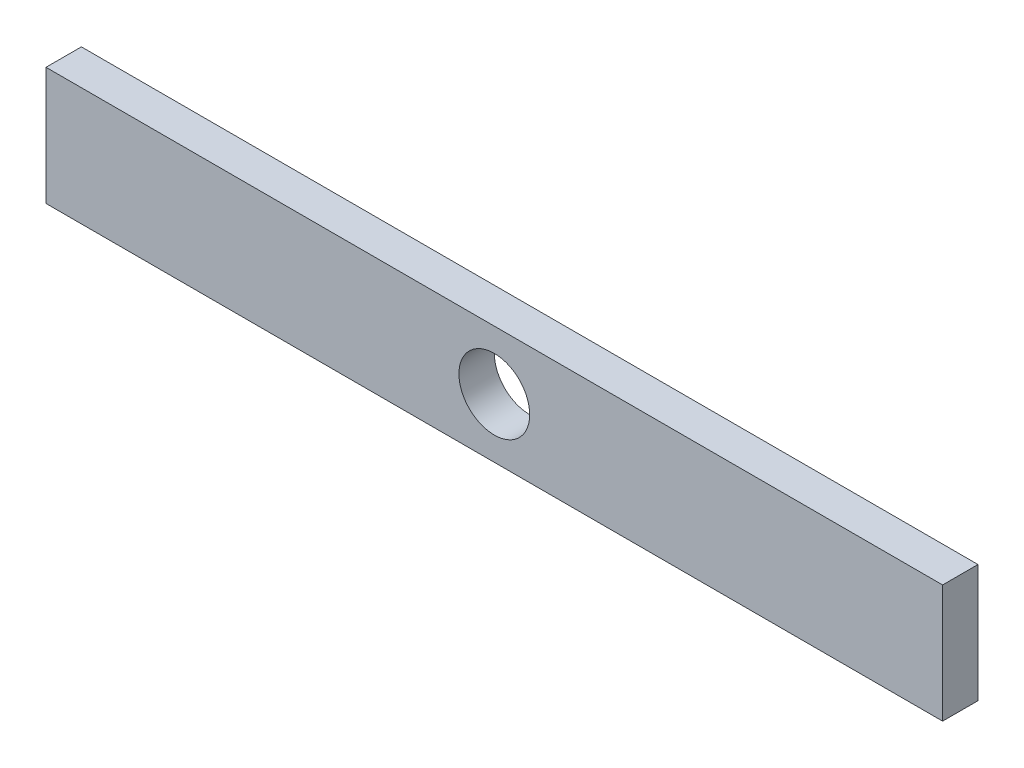
from build123d import *

# Parameters (mm, degrees)
SKETCH1_W           = 76
SKETCH1_H           = 10
SKETCH1_R           = 3
BOSS_EXTRUDE2_DEPTH = 3


with BuildPart() as part:
    # Sketch1 → Boss-Extrude2 (new body)
    with BuildSketch(Plane.XY):
        with Locations((7.772465562, 5)):
            Rectangle(SKETCH1_W, SKETCH1_H)
        with Locations((7.772465562, 5)):
            Circle(SKETCH1_R, mode=Mode.SUBTRACT)
    extrude(amount=BOSS_EXTRUDE2_DEPTH)


solid = part.part
